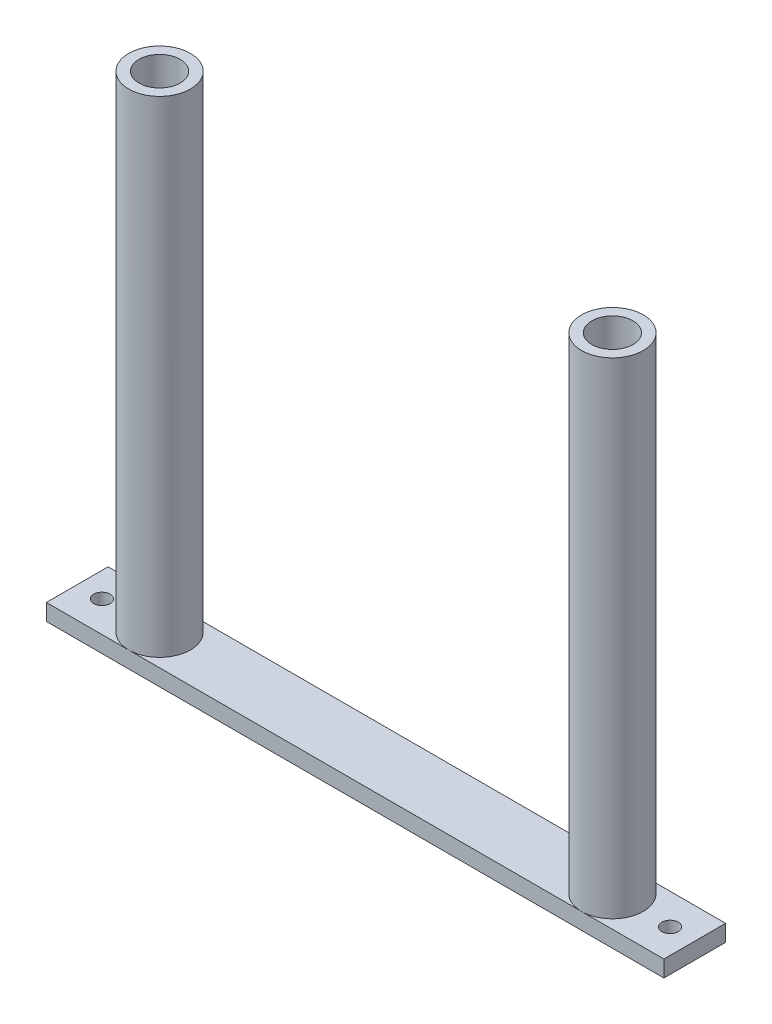
from build123d import *

# Parameters (mm, degrees)
SKETCH1_W           = 50.8
SKETCH1_H           = 19.05
BOSS_EXTRUDE1_DEPTH = 5.08
SKETCH2_R           = 9.525
BOSS_EXTRUDE2_DEPTH = 149.86
SKETCH3_R           = 6.35
CUT_EXTRUDE1_DEPTH  = 81.28
SKETCH4_R           = 1.27
CUT_EXTRUDE2_DEPTH  = 10.525
SKETCH6_W           = 44.45
SKETCH6_H           = 5.08
BOSS_EXTRUDE3_DEPTH = 19.05
SKETCH7_R           = 2.54
CUT_EXTRUDE3_DEPTH  = 6.08


with BuildPart() as part:
    # Sketch1 → Boss-Extrude1 (new body)
    with BuildSketch(Plane(origin=(0, 0, 0), x_dir=(1, 0, 0), z_dir=(0, 1, 0))):
        Rectangle(SKETCH1_W, SKETCH1_H)
    extrude(amount=BOSS_EXTRUDE1_DEPTH)

    # Sketch2 → Boss-Extrude2 (add)
    with BuildSketch(Plane(origin=(0, 5.08, 0), x_dir=(1, 0, 0), z_dir=(0, 1, 0))):
        Circle(SKETCH2_R)
    extrude(amount=BOSS_EXTRUDE2_DEPTH)

    # Sketch3 → Cut-Extrude1 (cut)
    with BuildSketch(Plane(origin=(0, 154.94, 0), x_dir=(1, 0, 0), z_dir=(0, 1, 0))):
        Circle(SKETCH3_R)
    extrude(amount=-CUT_EXTRUDE1_DEPTH, mode=Mode.SUBTRACT)

    # Sketch4 → Cut-Extrude2 (cut, through all)
    with BuildSketch(Plane.XY):
        with Locations((0, 130.81)):
            Circle(SKETCH4_R)
        with Locations((0, 125.73)):
            Circle(SKETCH4_R)
        with Locations((0, 120.65)):
            Circle(SKETCH4_R)
        with Locations((0, 115.57)):
            Circle(SKETCH4_R)
        with Locations((0, 110.49)):
            Circle(SKETCH4_R)
        with Locations((0, 105.41)):
            Circle(SKETCH4_R)
        with Locations((0, 100.33)):
            Circle(SKETCH4_R)
        with Locations((0, 95.25)):
            Circle(SKETCH4_R)
        with Locations((0, 74.93)):
            Circle(SKETCH4_R)
        with Locations((0, 80.01)):
            Circle(SKETCH4_R)
        with Locations((0, 85.09)):
            Circle(SKETCH4_R)
        with Locations((0, 90.17)):
            Circle(SKETCH4_R)
    extrude(amount=-CUT_EXTRUDE2_DEPTH, mode=Mode.SUBTRACT)

    # Sketch6 → Boss-Extrude3 (add, through all)
    with BuildSketch(Plane.XY.offset(9.525)):
        with Locations((47.625, 2.54)):
            Rectangle(SKETCH6_W, SKETCH6_H)
    extrude(amount=-BOSS_EXTRUDE3_DEPTH)

    # Mirror3: part across plane


with BuildPart() as part_1:
    add(part.part)
    add(part.part.mirror(Plane(origin=(69.85, 0, 0), x_dir=(0, 0, 1), z_dir=(1, 0, 0))))

    # Sketch7 → Cut-Extrude3 (cut, through all)
    with BuildSketch(Plane(origin=(0, 5.08, 0), x_dir=(1, 0, 0), z_dir=(0, 1, 0))):
        with Locations((-17.78, 0)):
            Circle(SKETCH7_R)
        with Locations((157.48, 0)):
            Circle(SKETCH7_R)
    extrude(amount=-CUT_EXTRUDE3_DEPTH, mode=Mode.SUBTRACT)


solid = part_1.part
